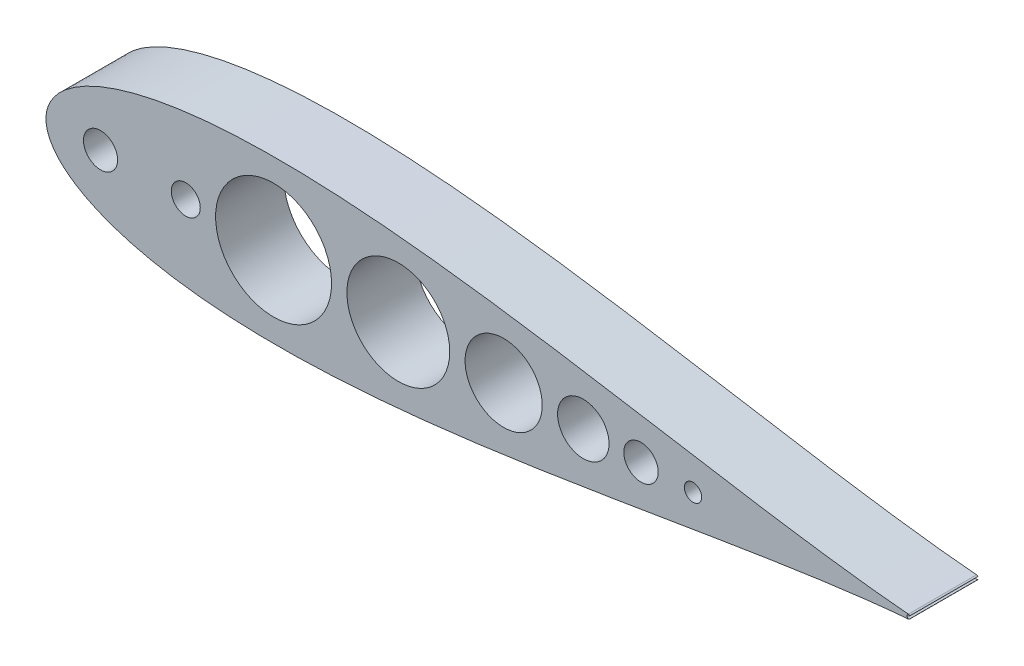
from build123d import *

# Parameters (mm, degrees)
BOSS_EXTRUDE1_DEPTH = 50.8
CUT_EXTRUDE2_START  = -51.8000001
CUT_EXTRUDE2_DEPTH  = 52.8000002


with BuildPart() as part:
    # Sketch2 → Boss-Extrude1 (new body)
    with BuildSketch(Plane.XY):
        with BuildLine():
            ThreePointArc((642.510849283, -1.582039112), (643.111845681, -1.408373102), (643.599082689, -1.016))
            ThreePointArc((643.599082689, -1.016), (642.269121423, -1.135922533), (641.567082689, 0))
            Line((641.567082689, 0), (473.360965279, 0))
            Line((473.360965279, 0), (460.660965279, 0))
            Line((460.660965279, 0), (114.935, 0))
            ThreePointArc((114.935, 0), (104.14, -10.795), (93.345, 0))
            Line((93.345, 0), (53.34, 0))
            ThreePointArc((53.34, 0), (40.64, -12.7), (27.94, 0))
            Line((27.94, 0), (0, 0))
            add(Edge.make_bspline(
                [(0, 0), (0, -1.007496172), (0.154611582, -3.513796615), (1.106333228, -7.923389435), (3.463136343, -13.420354421), (7.689616489, -19.513207632), (13.932423524, -25.726412106), (22.129107375, -31.731455339), (32.141645239, -37.332204029), (43.82045433, -42.41500246), (57.023709725, -46.912543066), (71.619696083, -50.784752003), (87.485018636, -54.008935199), (104.502313427, -56.574303932), (122.558104573, -58.481758104), (141.542033828, -59.739895824), (161.345829027, -60.366961324), (181.863132616, -60.387506142), (202.989192599, -59.8341217), (224.620860897, -58.745176641), (246.65655865, -57.164603829), (268.996310773, -55.141201012), (291.541767704, -52.727712704), (314.196207315, -49.979843895), (336.86454415, -46.955447457), (359.453314895, -43.713502532), (381.870662856, -40.313266856), (404.02631566, -36.813220545), (425.831595832, -33.270324121), (447.199424328, -29.739007432), (468.044367735, -26.27043606), (488.282710288, -22.911672601), (507.832591566, -19.705111663), (526.614143658, -16.687720753), (544.549749946, -13.890665375), (561.564270734, -11.338919625), (577.585454095, -9.050636147), (592.543922516, -7.037634907), (606.374988512, -5.304428983), (619.014124193, -3.849253664), (630.413817462, -2.663385493), (638.093728429, -1.953546407), (641.993392355, -1.625070631), (642.510849283, -1.582039112)],
                knots=[0.5, 0.5, 0.5, 0.5, 0.502166769, 0.505390167, 0.509655974, 0.514947682, 0.521244711, 0.528520886, 0.536744945, 0.54588136, 0.555890751, 0.566730119, 0.57835299, 0.590709588, 0.603747039, 0.617409572, 0.631638768, 0.646373793, 0.661551658, 0.677107483, 0.692974771, 0.709085713, 0.725371443, 0.741762353, 0.758188398, 0.774579367, 0.790865214, 0.806976332, 0.822843867, 0.838400002, 0.853578262, 0.868313774, 0.882543568, 0.896206835, 0.909245173, 0.92160287, 0.933227116, 0.944068236, 0.954079898, 0.963219316, 0.971447445, 0.978729112, 0.979842958, 0.979842958, 0.979842958, 0.979842958], degree=3))
        make_face()
    boss_extrude1 = extrude(amount=BOSS_EXTRUDE1_DEPTH)

    # Sketch3 → Cut-Extrude2 (cut)
    with BuildSketch(Plane.XY.offset(50.8).offset(CUT_EXTRUDE2_START)):
        with BuildLine():
            ThreePointArc((212.767950148, 0), (169.566475074, 43.201475074), (126.365, 0))
            Line((126.365, 0), (212.767950148, 0))
        make_face()
        with BuildLine():
            Line((212.767950148, 0), (126.365, 0))
            ThreePointArc((126.365, 0), (169.566475074, -43.201475074), (212.767950148, 0))
        make_face()
        with BuildLine():
            ThreePointArc((300.809151759, 0), (262.503550953, 38.305600806), (224.197950148, 0))
            Line((224.197950148, 0), (300.809151759, 0))
        make_face()
        with BuildLine():
            Line((300.809151759, 0), (224.197950148, 0))
            ThreePointArc((224.197950148, 0), (262.503550953, -38.305600806), (300.809151759, 0))
        make_face()
        with BuildLine():
            ThreePointArc((369.720663748, 0), (340.979907754, 28.740755995), (312.239151759, 0))
            Line((312.239151759, 0), (369.720663748, 0))
        make_face()
        with BuildLine():
            Line((369.720663748, 0), (312.239151759, 0))
            ThreePointArc((312.239151759, 0), (340.979907754, -28.740755995), (369.720663748, 0))
        make_face()
        with BuildLine():
            ThreePointArc((381.150663748, 0), (400.327663748, -19.177), (419.504663748, 0))
            Line((419.504663748, 0), (381.150663748, 0))
        make_face()
        with BuildLine():
            Line((381.150663748, 0), (419.504663748, 0))
            ThreePointArc((419.504663748, 0), (400.327663748, 19.177), (381.150663748, 0))
        make_face()
        with BuildLine():
            ThreePointArc((430.474866123, 0), (443.301866123, -12.827), (456.128866123, 0))
            Line((456.128866123, 0), (430.474866123, 0))
        make_face()
        with BuildLine():
            Line((430.474866123, 0), (456.128866123, 0))
            ThreePointArc((456.128866123, 0), (443.301866123, 12.827), (430.474866123, 0))
        make_face()
        with BuildLine():
            ThreePointArc((475.605534569, 0), (482.082534569, -6.477), (488.559534569, 0))
            Line((488.559534569, 0), (475.605534569, 0))
        make_face()
        with BuildLine():
            Line((475.605534569, 0), (488.559534569, 0))
            ThreePointArc((488.559534569, 0), (482.082534569, 6.477), (475.605534569, 0))
        make_face()
    cut_extrude2 = extrude(amount=CUT_EXTRUDE2_DEPTH, mode=Mode.SUBTRACT)

    # Mirror1: Boss-Extrude1, Cut-Extrude2 across plane
    add(boss_extrude1.mirror(Plane.ZX))
    add(cut_extrude2.mirror(Plane.ZX), mode=Mode.SUBTRACT)


solid = part.part
